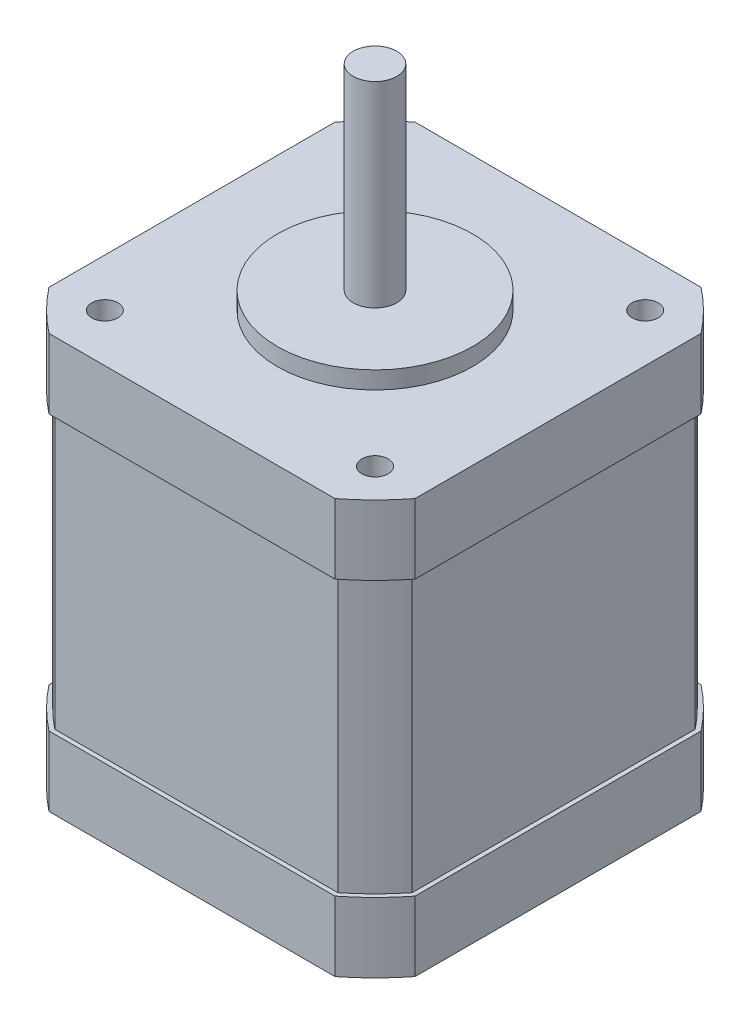
from build123d import *

# Parameters (mm, degrees)
BOSS_EXTRUDE1_DEPTH = 47.5
SKETCH2_R           = 1.5
CUT_EXTRUDE1_DEPTH  = 8
SKETCH3_R           = 11.2
BOSS_EXTRUDE2_DEPTH = 2
SKETCH4_R           = 2.5
BOSS_EXTRUDE3_DEPTH = 22.5
CUT_EXTRUDE2_START  = -8
SKETCH5_OUTSIDE_W   = 62.668
SKETCH5_OUTSIDE_H   = 62.668
CUT_EXTRUDE2_DEPTH  = 31.5


with BuildPart() as part:
    # Sketch1 → Boss-Extrude1 (new body)
    with BuildSketch(Plane(origin=(0, 0, 0), x_dir=(1, 0, 0), z_dir=(0, 1, 0))):
        with BuildLine():
            Line((-16.408001097, 21), (16.408001097, 21))
            ThreePointArc((16.408001097, 21), (18.844395719, 18.844395719), (21, 16.408001097))
            Line((21, 16.408001097), (21, -16.408001097))
            ThreePointArc((21, -16.408001097), (18.844395719, -18.844395719), (16.408001097, -21))
            Line((16.408001097, -21), (-16.408001097, -21))
            ThreePointArc((-16.408001097, -21), (-18.844395719, -18.844395719), (-21, -16.408001097))
            Line((-21, -16.408001097), (-21, 16.408001097))
            ThreePointArc((-21, 16.408001097), (-18.844395719, 18.844395719), (-16.408001097, 21))
        make_face()
    extrude(amount=BOSS_EXTRUDE1_DEPTH)

    # Sketch2 → Cut-Extrude1 (cut)
    with BuildSketch(Plane(origin=(0, 47.5, 0), x_dir=(1, 0, 0), z_dir=(0, 1, 0))):
        with Locations((-15.499780644, 15.499780644)):
            Circle(SKETCH2_R)
        with Locations((-15.499780644, -15.499780644)):
            Circle(SKETCH2_R)
        with Locations((15.499780644, -15.499780644)):
            Circle(SKETCH2_R)
        with Locations((15.499780644, 15.499780644)):
            Circle(SKETCH2_R)
    extrude(amount=-CUT_EXTRUDE1_DEPTH, mode=Mode.SUBTRACT)

    # Sketch3 → Boss-Extrude2 (add)
    with BuildSketch(Plane(origin=(0, 47.5, 0), x_dir=(1, 0, 0), z_dir=(0, 1, 0))):
        Circle(SKETCH3_R)
    extrude(amount=BOSS_EXTRUDE2_DEPTH)

    # Sketch4 → Boss-Extrude3 (add)
    with BuildSketch(Plane(origin=(0, 49.5, 0), x_dir=(1, 0, 0), z_dir=(0, 1, 0))):
        Circle(SKETCH4_R)
    extrude(amount=BOSS_EXTRUDE3_DEPTH)

    # Sketch5 outside → Cut-Extrude2 (cut)
    with BuildSketch(Plane(origin=(0, 47.5, 0), x_dir=(1, 0, 0), z_dir=(0, 1, 0)).offset(CUT_EXTRUDE2_START)):
        Rectangle(SKETCH5_OUTSIDE_W, SKETCH5_OUTSIDE_H)
        with BuildLine():
            Line((-20.5, 16.234916076), (-20.5, -16.234916076))
            ThreePointArc((-20.5, -16.234916076), (-18.490842328, -18.490842328), (-16.234916076, -20.5))
            Line((-16.234916076, -20.5), (16.234916076, -20.5))
            ThreePointArc((16.234916076, -20.5), (18.490842328, -18.490842328), (20.5, -16.234916076))
            Line((20.5, -16.234916076), (20.5, 16.234916076))
            ThreePointArc((20.5, 16.234916076), (18.490842328, 18.490842328), (16.234916076, 20.5))
            Line((16.234916076, 20.5), (-16.234916076, 20.5))
            ThreePointArc((-16.234916076, 20.5), (-18.490842328, 18.490842328), (-20.5, 16.234916076))
        make_face(mode=Mode.SUBTRACT)
    extrude(amount=-CUT_EXTRUDE2_DEPTH, mode=Mode.SUBTRACT)


solid = part.part
